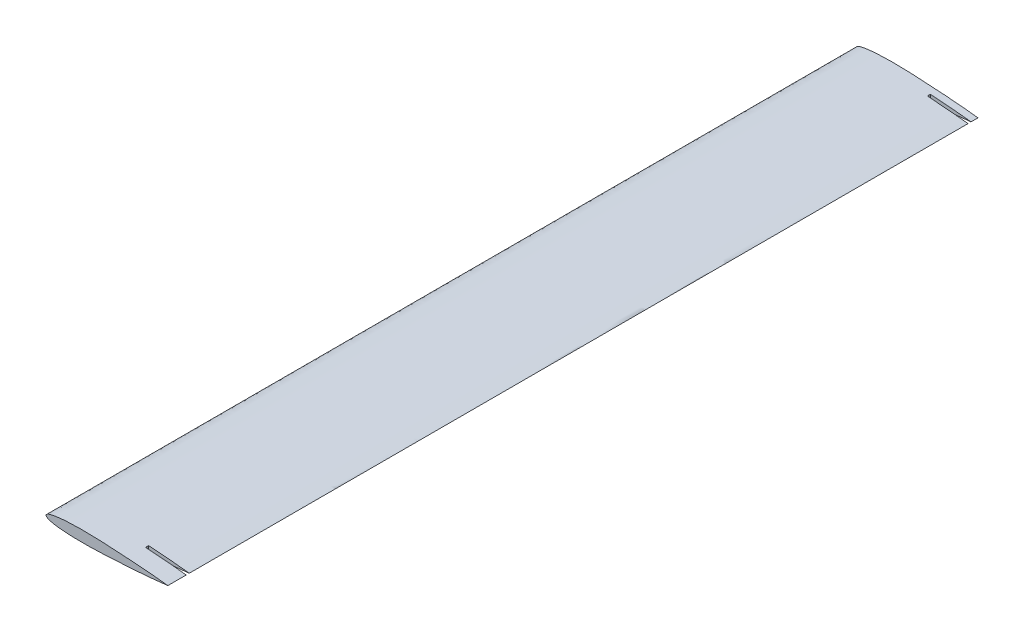
from build123d import *

# Parameters (mm, degrees)
BOSS_EXTRUDE1_DEPTH     = 1330
SKETCH3_W               = 78.393694994
SKETCH3_H               = 5
SKETCH3_W_2             = 197.338646123
CUT_EXTRUDE1_DEPTH      = 236
CUT_EXTRUDE1_DEPTH_BACK = 195


with BuildPart() as part:
    # Sketch1 → Boss-Extrude1 (new body)
    with BuildSketch(Plane.XY):
        with BuildLine():
            add(Edge.make_bspline(
                [(200, 0), (200, 0.038208179), (198.173049044, 0.19022505), (196.299321828, 0.507442706), (191.74790241, 0.993763141), (186.155835511, 1.597424839), (178.869410335, 2.305816721), (170.314746269, 3.087573551), (160.529272094, 3.92759907), (149.717754924, 4.801312359), (138.052566355, 5.673814465), (125.737106614, 6.519252588), (112.981210062, 7.298723884), (100.003286779, 7.979219047), (87.024927754, 8.520286322), (76.308652125, 8.832851856), (67.90234379, 8.976442267), (61.786774306, 9.027401842), (55.834416019, 9.020283411), (50.070727516, 8.943660593), (44.520838848, 8.809162096), (39.208974434, 8.606040244), (34.157459026, 8.341691171), (29.387255791, 8.009952664), (24.918591532, 7.616438025), (20.772045952, 7.157701782), (16.964902636, 6.642489305), (13.512047693, 6.08408238), (10.427861272, 5.484982095), (7.722362477, 4.847264677), (5.408363455, 4.149453708), (3.490886808, 3.378624359), (1.987477258, 2.528120237), (0.906342383, 1.640006236), (0.231166119, 0.826014489), (-0.094593139, 0), (0.231166119, -0.826014489), (0.906342383, -1.640006236), (1.987477258, -2.528120237), (3.490886808, -3.378624359), (5.408363455, -4.149453708), (7.722362477, -4.847264677), (10.427861272, -5.484982095), (13.512047693, -6.08408238), (16.964902636, -6.642489305), (20.772045952, -7.157701782), (24.918591532, -7.616438025), (29.387255791, -8.009952664), (34.157459026, -8.341691171), (39.208974434, -8.606040244), (44.520838848, -8.809162096), (50.070727516, -8.943660593), (55.834416019, -9.020283411), (61.786774306, -9.027401842), (67.90234379, -8.976442267), (76.308652125, -8.832851856), (87.024927754, -8.520286322), (100.003286779, -7.979219047), (112.981210062, -7.298723884), (125.737106614, -6.519252588), (138.052566355, -5.673814465), (149.717754924, -4.801312359), (160.529272094, -3.92759907), (170.314746269, -3.087573551), (178.869410335, -2.305816721), (186.155835511, -1.597424839), (191.74790241, -0.993763141), (196.299321828, -0.507442706), (198.173049044, -0.19022505), (200, -0.038208179), (200, 0)],
                knots=[0, 0, 0, 0, 0.002133427, 0.008488156, 0.018944487, 0.033319114, 0.051356294, 0.072756093, 0.097140817, 0.124097489, 0.153162557, 0.183833918, 0.215589374, 0.247878195, 0.280150868, 0.311860397, 0.327332943, 0.342462846, 0.357187102, 0.371448118, 0.385183441, 0.398331273, 0.410844637, 0.422672607, 0.433769314, 0.444090175, 0.453589412, 0.46224044, 0.470010037, 0.476870985, 0.482833353, 0.487908551, 0.492155164, 0.495592273, 0.498196359, 0.5, 0.501803641, 0.504407727, 0.507844836, 0.512091449, 0.517166647, 0.523129015, 0.529989963, 0.53775956, 0.546410588, 0.555909825, 0.566230686, 0.577327393, 0.589155363, 0.601668727, 0.614816559, 0.628551882, 0.642812898, 0.657537154, 0.672667057, 0.688139603, 0.719849132, 0.752121805, 0.784410626, 0.816166082, 0.846837443, 0.875902511, 0.902859183, 0.927243907, 0.948643706, 0.966680886, 0.981055513, 0.991511844, 0.997866573, 1, 1, 1, 1], degree=3))
        make_face()
    extrude(amount=BOSS_EXTRUDE1_DEPTH)

    # Sketch3 → Cut-Extrude1 (cut, two sides)
    with BuildSketch(Plane(origin=(0, 0, 0), x_dir=(1, 0, 0), z_dir=(0, 1, 0))) as cut_extrude1_sk:
        with Locations((172.585640536, -13.949359743)):
            Rectangle(SKETCH3_W, SKETCH3_H)
        with Locations((232.058116101, -1297.33749619)):
            Rectangle(SKETCH3_W_2, SKETCH3_H)
    extrude(amount=CUT_EXTRUDE1_DEPTH, mode=Mode.SUBTRACT)
    extrude(cut_extrude1_sk.sketch, amount=-CUT_EXTRUDE1_DEPTH_BACK, mode=Mode.SUBTRACT)


solid = part.part
